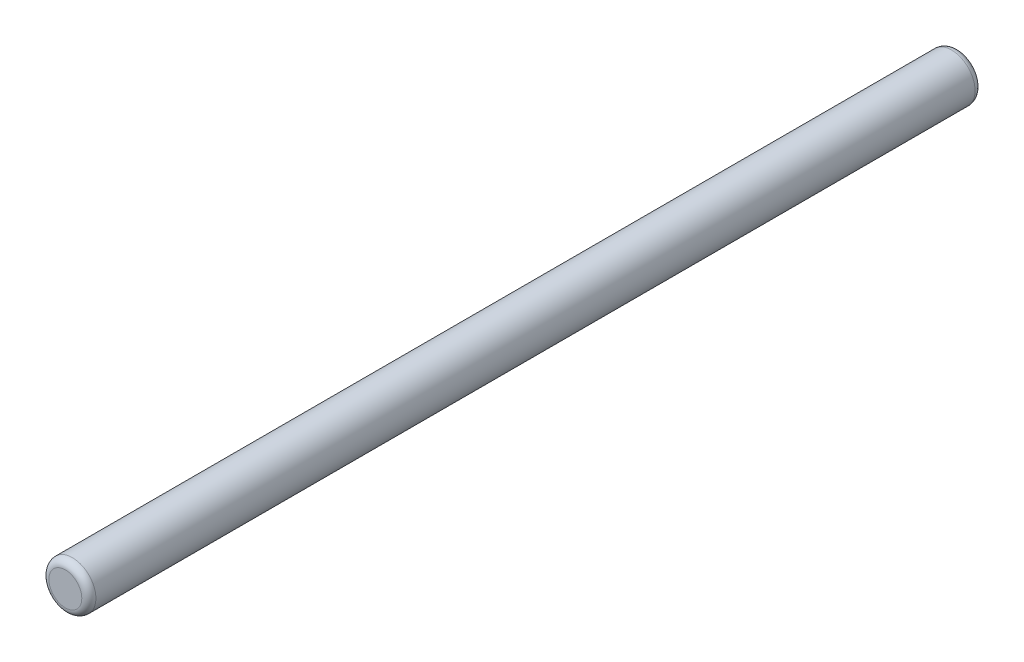
from build123d import *

# Parameters (mm, degrees)
ESQUISSE1_R          = 1
BASE_EXTRUSION_DEPTH = 38
CONG_1_R             = 0.3


with BuildPart() as part:
    # Esquisse1 → Base-Extrusion (new body)
    with BuildSketch(Plane.XY):
        Circle(ESQUISSE1_R)
    extrude(amount=BASE_EXTRUSION_DEPTH)

    # Congé1
    cong_1_edges = [part.edges().sort_by_distance(p)[0] for p in [
        (-1, 0, 0),
        (-1, 0, 38),
    ]]
    fillet(cong_1_edges, radius=CONG_1_R)


solid = part.part
